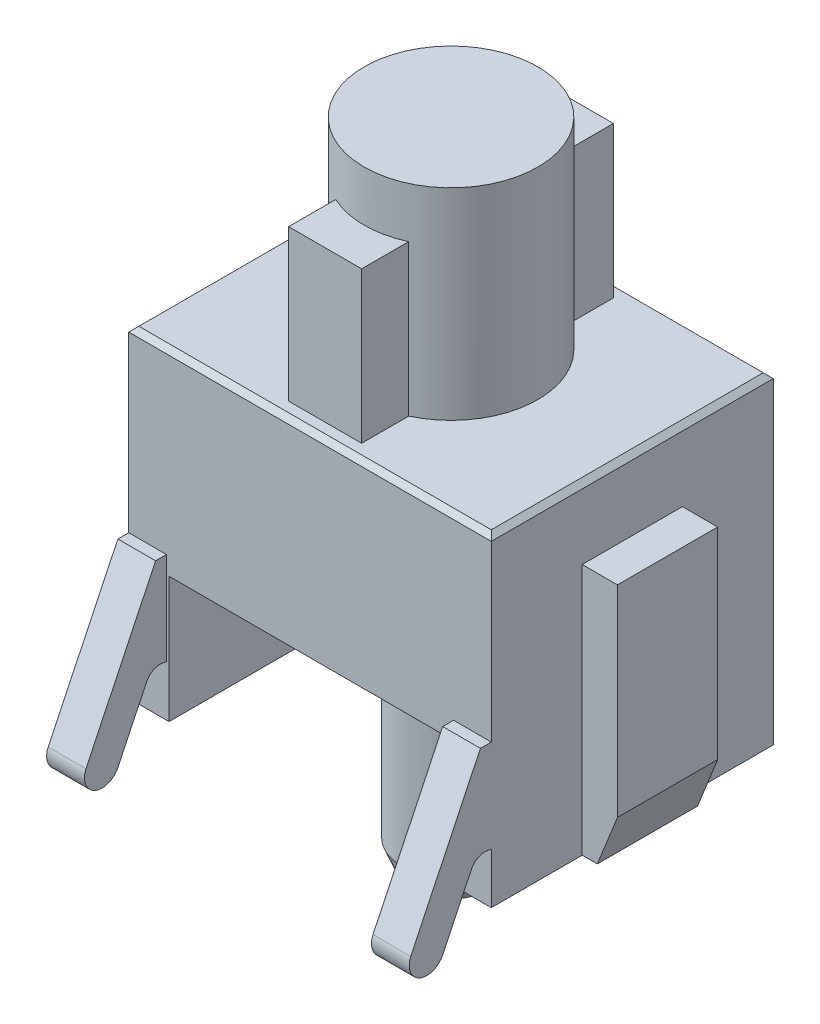
from build123d import *

# Parameters (mm, degrees)
SKETCH1_W                = 7.2
SKETCH1_H                = 5.6
BODY_DEPTH               = 6.4
BODY_CHAMFER_SIZE        = 0.1
SKETCH2_R                = 1.725
MOUNT_DEPTH              = 4
SKETCH3_W                = 1.45
SKETCH3_H                = 5
MOUNT_RAILS_DEPTH        = 3
SKETCH4_R                = 2.25
BODY_CUT_1_DEPTH         = 4.8
SKETCH5_W                = 5.6
SKETCH5_H                = 5.6
BODY_CUT_2_DEPTH         = 2.5
SKETCH6_R                = 0.975
POLE_DEPTH               = 7.3
POLE_CHAMFER_SIZE        = 0.5
POLE_CHAMFER_SIZE2       = 0.2
SKETCH7_W                = 1.99
SKETCH7_H                = 5
RIGHT_RAIL_DEPTH         = 0.7
RIGHT_RAIL_CHAMFER_SIZE  = 0.4
RIGHT_RAIL_CHAMFER_SIZE2 = 1
LEFT_RAIL_CHAMFER_SIZE   = 1
LEFT_RAIL_CHAMFER_SIZE2  = 0.4
RIGHT_LEG_DEPTH          = 0.75


with BuildPart() as part:
    # Sketch1 → Body (new body)
    with BuildSketch(Plane(origin=(0, 0, 0), x_dir=(1, 0, 0), z_dir=(0, 1, 0))):
        Rectangle(SKETCH1_W, SKETCH1_H)
    extrude(amount=BODY_DEPTH)

    # Body Chamfer
    body_chamfer_edges = [part.edges().sort_by_distance(p)[0] for p in [
        (-3.6, 6.4, 0),
        (0, 6.4, 2.8),
        (3.6, 6.4, 0),
        (0, 6.4, -2.8),
    ]]
    chamfer(body_chamfer_edges, length=BODY_CHAMFER_SIZE)

    # Sketch2 → Mount (add)
    with BuildSketch(Plane(origin=(0, 6.4, 0), x_dir=(1, 0, 0), z_dir=(0, 1, 0))):
        Circle(SKETCH2_R)
    extrude(amount=MOUNT_DEPTH)

    # Sketch3 → Mount Rails (add)
    with BuildSketch(Plane(origin=(0, 6.4, 0), x_dir=(1, 0, 0), z_dir=(0, 1, 0))):
        Rectangle(SKETCH3_W, SKETCH3_H)
    extrude(amount=MOUNT_RAILS_DEPTH)

    # Sketch4 → Body Cut 1 (cut)
    with BuildSketch(Plane.XZ):
        Circle(SKETCH4_R)
    extrude(amount=-BODY_CUT_1_DEPTH, mode=Mode.SUBTRACT)

    # Sketch5 → Body Cut 2 (cut)
    with BuildSketch(Plane.XZ):
        Rectangle(SKETCH5_W, SKETCH5_H)
    extrude(amount=-BODY_CUT_2_DEPTH, mode=Mode.SUBTRACT)

    # Sketch6 → Pole (add)
    with BuildSketch(Plane.XZ.offset(-4.8)):
        Circle(SKETCH6_R)
    extrude(amount=POLE_DEPTH)

    # Pole Chamfer
    pole_chamfer_edges = [part.edges().sort_by_distance(p)[0] for p in [
        (-0.975, -2.5, 0),
    ]]
    pole_chamfer_side = [part.faces().sort_by_distance(p)[0] for p in [
        (-0.975, 1.15, 0),
    ]]
    chamfer(pole_chamfer_edges, length=POLE_CHAMFER_SIZE, length2=POLE_CHAMFER_SIZE2, reference=pole_chamfer_side[0])

    # Sketch7 → Right Rail (add)
    with BuildSketch(Plane(origin=(3.6, 0, 0), x_dir=(0, 0, -1), z_dir=(1, 0, 0))):
        with Locations((0, 2.5)):
            Rectangle(SKETCH7_W, SKETCH7_H)
    right_rail = extrude(amount=RIGHT_RAIL_DEPTH)

    # Rail Mirror: Right Rail across plane
    add(right_rail.mirror(Plane(origin=(0, 0, 0), x_dir=(0, 0, 1), z_dir=(1, 0, 0))))

    # Right Rail Chamfer
    right_rail_chamfer_edges = [part.edges().sort_by_distance(p)[0] for p in [
        (4.3, 0, 0),
    ]]
    right_rail_chamfer_side = [part.faces().sort_by_distance(p)[0] for p in [
        (3.377890346, 0, 0),
    ]]
    chamfer(right_rail_chamfer_edges, length=RIGHT_RAIL_CHAMFER_SIZE, length2=RIGHT_RAIL_CHAMFER_SIZE2, reference=right_rail_chamfer_side[0])

    # Left Rail Chamfer
    left_rail_chamfer_edges = [part.edges().sort_by_distance(p)[0] for p in [
        (-4.3, 0, 0),
    ]]
    left_rail_chamfer_side = [part.faces().sort_by_distance(p)[0] for p in [
        (-4.3, 2.5, 0),
    ]]
    chamfer(left_rail_chamfer_edges, length=LEFT_RAIL_CHAMFER_SIZE, length2=LEFT_RAIL_CHAMFER_SIZE2, reference=left_rail_chamfer_side[0])

    # Sketch8 → Right Leg (add)
    with BuildSketch(Plane(origin=(3.6, 0, 0), x_dir=(0, 0, -1), z_dir=(1, 0, 0))):
        with BuildLine():
            Line((-3.016216216, 2.849166829), (-4.4, -0.036165464))
            ThreePointArc((-4.4, -0.036165464), (-4.221723875, -0.497920402), (-3.759968937, -0.319644277))
            Line((-3.759968937, -0.319644277), (-3.197806774, 0.852521967))
            ThreePointArc((-3.197806774, 0.852521967), (-3.029447088, 1.008649464), (-2.8, 1))
            Line((-2.8, 1), (-2.8, 2.849166829))
            Line((-2.8, 2.849166829), (-3.016216216, 2.849166829))
        make_face()
    right_leg = extrude(amount=-RIGHT_LEG_DEPTH)

    # Leg Mirror: Right Leg across plane
    add(right_leg.mirror(Plane(origin=(0, 0, 0), x_dir=(0, 0, 1), z_dir=(1, 0, 0))))


solid = part.part
